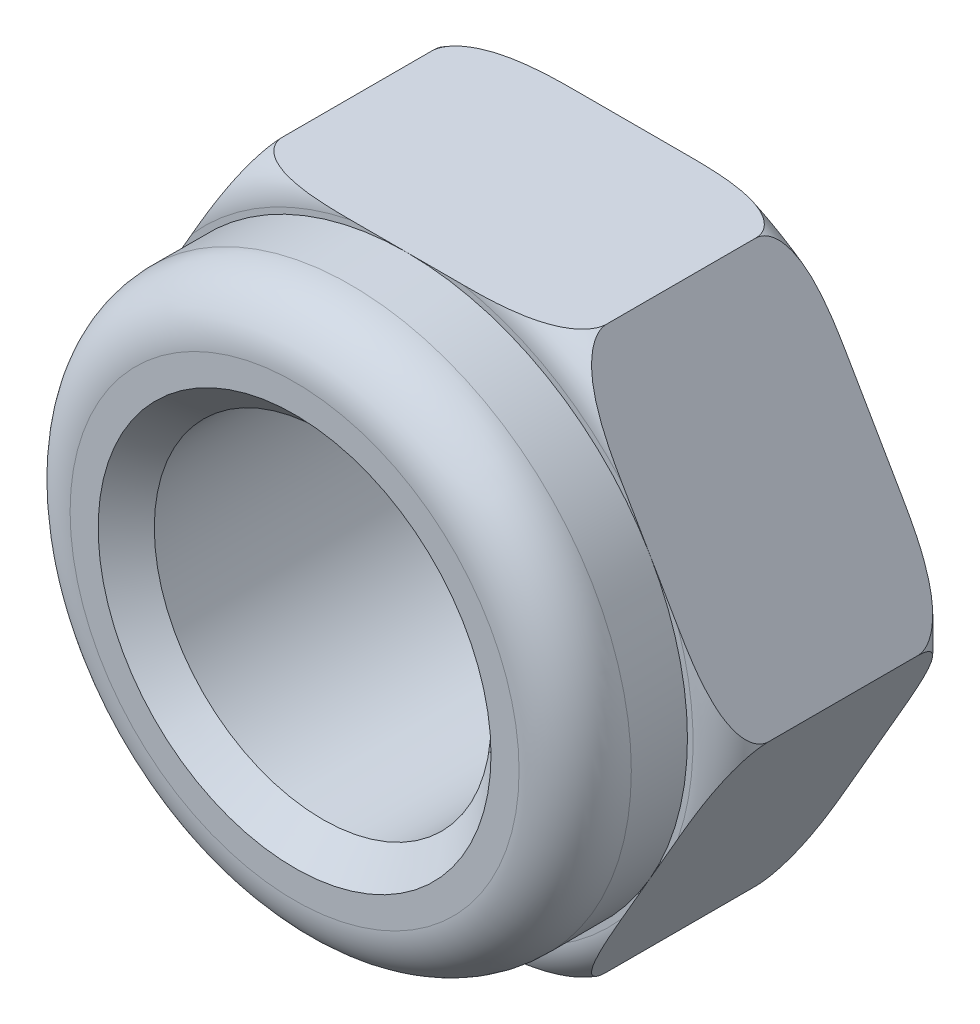
from build123d import *

# Parameters (mm, degrees)
SZKIC1_R                    = 3
DODANIE_WYCI_GNI_CIE1_DEPTH = 4
SZKIC2_R                    = 5
SZKIC2_R_2                  = 3
DODANIE_WYCI_GNI_CIE2_DEPTH = 6
SFAZOWANIE1_SIZE            = 0.5


with BuildPart() as part:
    # Szkic1 → Dodanie-wyciągnięcie1 (new body)
    with BuildSketch(Plane.XY):
        Polygon((-5.773502692, 0), (-2.886751346, -5), (2.886751346, -5), (5.773502692, 0), (2.886751346, 5), (-2.886751346, 5), align=None)
        Circle(SZKIC1_R, mode=Mode.SUBTRACT)
    extrude(amount=DODANIE_WYCI_GNI_CIE1_DEPTH)

    # Szkic2 → Dodanie-wyciągnięcie2 (add)
    with BuildSketch(Plane.XY):
        Circle(SZKIC2_R)
        Circle(SZKIC2_R_2, mode=Mode.SUBTRACT)
    extrude(amount=DODANIE_WYCI_GNI_CIE2_DEPTH)

    # Sfazowanie1
    sfazowanie1_edges = [part.edges().sort_by_distance(p)[0] for p in [
        (-3, 0, 0),
        (-3, 0, 6),
    ]]
    chamfer(sfazowanie1_edges, length=SFAZOWANIE1_SIZE)

    # Szkic3 → Wycięcie-obrót1 (revolve, cut)
    with BuildSketch(Plane(origin=(0, 0, 0), x_dir=(1, 0, 0), z_dir=(0, 1, 0))):
        with BuildLine():
            Line((-5.773502692, 0), (-5.773502692, -0.673502692))
            ThreePointArc((-5.773502692, -0.673502692), (-5.576238321, -0.197264371), (-5.1, 0))
            Line((-5.1, 0), (-5.773502692, 0))
        make_face()
        with BuildLine():
            ThreePointArc((-5.1, -4), (-5.576238321, -3.802735629), (-5.773502692, -3.326497308))
            Line((-5.773502692, -3.326497308), (-5.773502692, -4))
            Line((-5.773502692, -4), (-5.1, -4))
        make_face()
        with BuildLine():
            Line((-5, -6), (-4, -6))
            ThreePointArc((-4, -6), (-4.707106781, -5.707106781), (-5, -5))
            Line((-5, -5), (-5, -6))
        make_face()
    revolve(axis=Axis((0, 0, -1.701574894), (0, 0, 1)), mode=Mode.SUBTRACT)


solid = part.part
